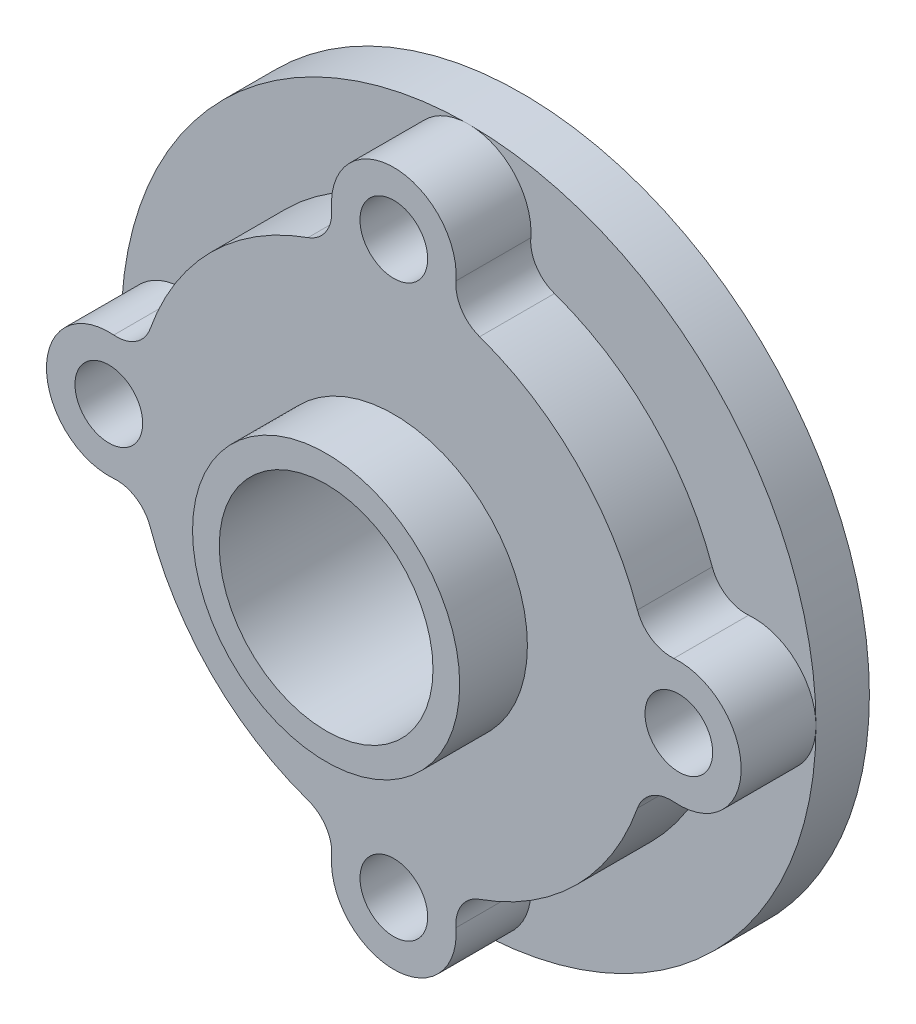
from build123d import *

# Parameters (mm, degrees)
SKETCH_1_R          = 97.5
EXTRUDE_1_DEPTH     = 15
SKETCH_2_R          = 72.5
EXTRUDE_2_DEPTH     = 21
SKETCH_3_R          = 67.5
EXTRUDE_3_DEPTH     = 12
SKETCH_4_R          = 37.5
EXTRUDE_4_DEPTH     = 19
CUT_EXTRUDE_1_REACH = 69
SKETCH_5_R          = 30
SKETCH_6_R          = 57.5
CUT_EXTRUDE_2_DEPTH = 5
SKETCH_7_R          = 57.5
SKETCH_7_R_2        = 37.5
CUT_EXTRUDE_3_DEPTH = 20
EXTRUDE_5_DEPTH     = 21
SKETCH_9_R          = 9.5
CUT_EXTRUDE_4_DEPTH = 36


with BuildPart() as part:
    # 草图1 → 凸台-拉伸1 (new body)
    with BuildSketch(Plane.XY):
        Circle(SKETCH_1_R)
    extrude(amount=EXTRUDE_1_DEPTH)

    # 草图2 → 凸台-拉伸2 (add)
    with BuildSketch(Plane.XY.offset(15)):
        Circle(SKETCH_2_R)
    extrude(amount=EXTRUDE_2_DEPTH)

    # 草图3 → 凸台-拉伸3 (add)
    with BuildSketch(Plane(origin=(0, 0, 0), x_dir=(-1, 0, 0), z_dir=(0, 0, -1))):
        Circle(SKETCH_3_R)
    extrude(amount=EXTRUDE_3_DEPTH)

    # 草图4 → 凸台-拉伸4 (add)
    with BuildSketch(Plane.XY.offset(36)):
        Circle(SKETCH_4_R)
    extrude(amount=EXTRUDE_4_DEPTH)

    # 草图5 → 切除-拉伸1 (cut, up to next)
    with BuildSketch(Plane.XY.offset(55), mode=Mode.PRIVATE) as cut_extrude_1_sk1:
        Circle(SKETCH_5_R)
    cut_extrude_1_tool1 = extrude(cut_extrude_1_sk1.sketch, amount=-CUT_EXTRUDE_1_REACH, mode=Mode.PRIVATE) & part.part
    add(cut_extrude_1_tool1.solids().sort_by_distance((0, 0, 55))[0], mode=Mode.SUBTRACT)

    # 草图6 → 切除-拉伸2 (cut)
    with BuildSketch(Plane(origin=(0, 0, -12), x_dir=(-1, 0, 0), z_dir=(0, 0, -1))):
        Circle(SKETCH_6_R)
    extrude(amount=-CUT_EXTRUDE_2_DEPTH, mode=Mode.SUBTRACT)

    # 草图7 → 切除-拉伸3 (cut)
    with BuildSketch(Plane(origin=(0, 0, -7), x_dir=(-1, 0, 0), z_dir=(0, 0, -1))):
        Circle(SKETCH_7_R)
        Circle(SKETCH_7_R_2, mode=Mode.SUBTRACT)
    extrude(amount=-CUT_EXTRUDE_3_DEPTH, mode=Mode.SUBTRACT)

    # 草图8 → 凸台-拉伸5 (add)
    with BuildSketch(Plane.XY.offset(15)):
        with BuildLine():
            ThreePointArc((17.444546697, 78.607954545), (0, 97.5), (-17.444546697, 78.607954545))
            ThreePointArc((-17.444546697, 78.607954545), (-19.027604179, 72.363876321), (-24.090088295, 68.380681818))
            ThreePointArc((-24.090088295, 68.380681818), (0, 72.5), (24.090088295, 68.380681818))
            ThreePointArc((24.090088295, 68.380681818), (19.027604179, 72.363876321), (17.444546697, 78.607954545))
        make_face()
        with BuildLine():
            ThreePointArc((78.607954545, -17.444546697), (97.5, 0), (78.607954545, 17.444546697))
            ThreePointArc((78.607954545, 17.444546697), (72.363876321, 19.027604179), (68.380681818, 24.090088295))
            ThreePointArc((68.380681818, 24.090088295), (72.5, 0), (68.380681818, -24.090088295))
            ThreePointArc((68.380681818, -24.090088295), (72.363876321, -19.027604179), (78.607954545, -17.444546697))
        make_face()
        with BuildLine():
            ThreePointArc((-17.444546697, -78.607954545), (0, -97.5), (17.444546697, -78.607954545))
            ThreePointArc((17.444546697, -78.607954545), (19.027604179, -72.363876321), (24.090088295, -68.380681818))
            ThreePointArc((24.090088295, -68.380681818), (0, -72.5), (-24.090088295, -68.380681818))
            ThreePointArc((-24.090088295, -68.380681818), (-19.027604179, -72.363876321), (-17.444546697, -78.607954545))
        make_face()
        with BuildLine():
            ThreePointArc((-78.607954545, 17.444546697), (-97.5, 0), (-78.607954545, -17.444546697))
            ThreePointArc((-78.607954545, -17.444546697), (-72.363876321, -19.027604179), (-68.380681818, -24.090088295))
            ThreePointArc((-68.380681818, -24.090088295), (-72.5, 0), (-68.380681818, 24.090088295))
            ThreePointArc((-68.380681818, 24.090088295), (-72.363876321, 19.027604179), (-78.607954545, 17.444546697))
        make_face()
    extrude(amount=EXTRUDE_5_DEPTH)

    # 草图9 → 切除-拉伸4 (cut)
    with BuildSketch(Plane.XY.offset(36)):
        with Locations((0, 80)):
            Circle(SKETCH_9_R)
        with Locations((80, 0)):
            Circle(SKETCH_9_R)
        with Locations((0, -80)):
            Circle(SKETCH_9_R)
        with Locations((-80, 0)):
            Circle(SKETCH_9_R)
    extrude(amount=-CUT_EXTRUDE_4_DEPTH, mode=Mode.SUBTRACT)


solid = part.part
